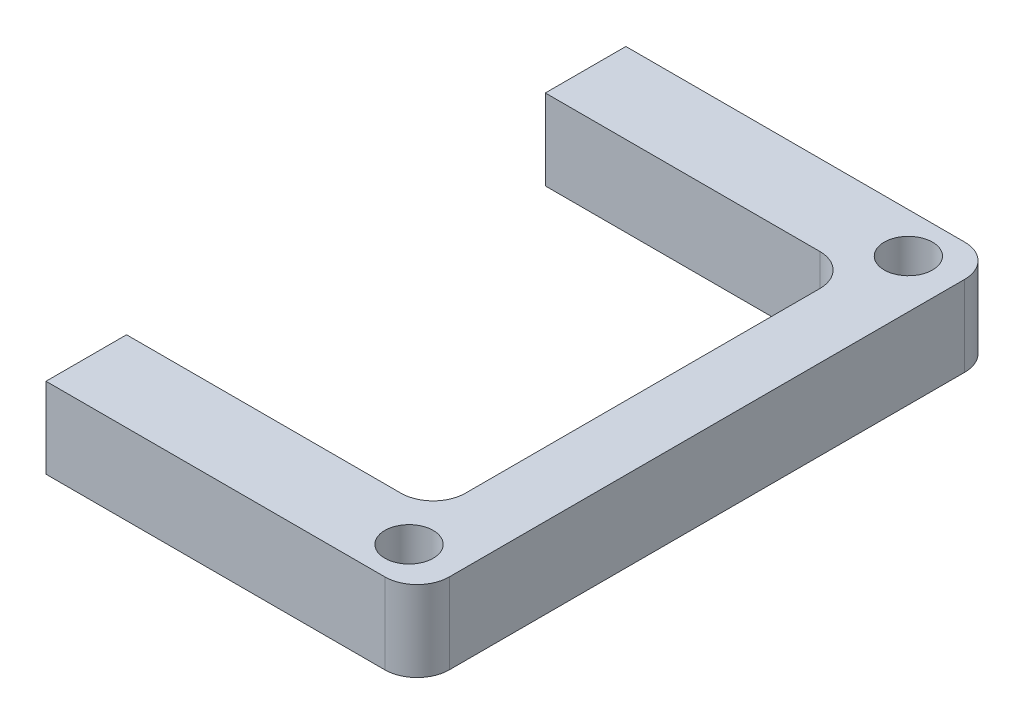
from build123d import *

# Parameters (mm, degrees)
SKETCH1_R           = 1.5
BOSS_EXTRUDE1_DEPTH = 5
FILLET1_R           = 2
SKETCH2_W           = 7.277082667
SKETCH2_H           = 36
CUT_EXTRUDE1_DEPTH  = 10


with BuildPart() as part:
    # Sketch1 → Boss-Extrude1 (new body)
    with BuildSketch(Plane(origin=(0, 0, 0), x_dir=(1, 0, 0), z_dir=(0, 1, 0))):
        Polygon((0, 31), (0, 36), (29, 36), (29, 0), (0, 0), (0, 5), (25, 5), (25, 31), align=None)
        with Locations((26, 2.5)):
            Circle(SKETCH1_R, mode=Mode.SUBTRACT)
        with Locations((26, 33.5)):
            Circle(SKETCH1_R, mode=Mode.SUBTRACT)
        with Locations((3, 33.5)):
            Circle(SKETCH1_R, mode=Mode.SUBTRACT)
        with Locations((3, 2.5)):
            Circle(SKETCH1_R, mode=Mode.SUBTRACT)
    extrude(amount=BOSS_EXTRUDE1_DEPTH)

    # Fillet1
    fillet1_edges = [part.edges().sort_by_distance(p)[0] for p in [
        (0, 2.5, -36),
        (29, 2.5, -36),
        (29, 2.5, 0),
        (0, 2.5, 0),
        (0, 2.5, -5),
        (25, 2.5, -5),
        (25, 2.5, -31),
        (0, 2.5, -31),
    ]]
    fillet(fillet1_edges, radius=FILLET1_R)

    # Sketch2 → Cut-Extrude1 (cut)
    with BuildSketch(Plane(origin=(0, 5, 0), x_dir=(1, 0, 0), z_dir=(0, 1, 0))):
        with Locations((2.323033499, 18)):
            Rectangle(SKETCH2_W, SKETCH2_H)
    extrude(amount=-CUT_EXTRUDE1_DEPTH, mode=Mode.SUBTRACT)


solid = part.part
